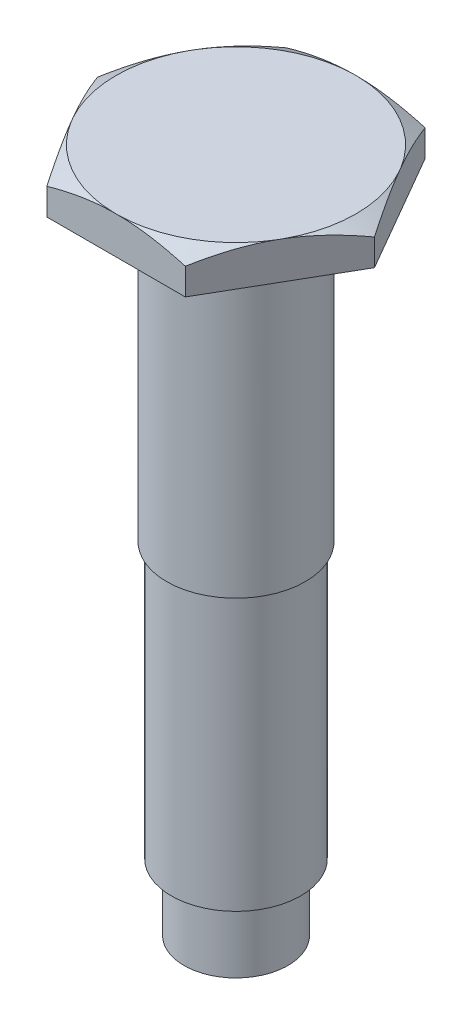
from build123d import *

# Parameters (mm, degrees)
BOSS_EXTRUDE1_DEPTH = 1.4
SKETCH2_OUTSIDE_W   = 18.618
SKETCH2_OUTSIDE_H   = 17.226
SKETCH2_OUTSIDE_R   = 4.5
CUT_EXTRUDE1_DEPTH  = 1
CUT_EXTRUDE1_TAPER  = 60
SKETCH3_R           = 2.425
BOSS_EXTRUDE2_DEPTH = 24.3
SKETCH4_OUTSIDE_W   = 18.218
SKETCH4_OUTSIDE_H   = 16.826
SKETCH4_OUTSIDE_R   = 1.95
CUT_EXTRUDE2_DEPTH  = 2.5
SKETCH5_R           = 2.6
BOSS_EXTRUDE3_DEPTH = 11.5


with BuildPart() as part:
    # Sketch1 → Boss-Extrude1 (new body)
    with BuildSketch(Plane(origin=(0, 0, 0), x_dir=(1, 0, 0), z_dir=(0, 1, 0))):
        Polygon((5.195, 0), (2.5975, 4.499001973), (-2.5975, 4.499001973), (-5.195, 0), (-2.5975, -4.499001973), (2.5975, -4.499001973), align=None)
    extrude(amount=BOSS_EXTRUDE1_DEPTH)

    # Sketch2 outside → Cut-Extrude1 (cut)
    with BuildSketch(Plane(origin=(0, 1.4, 0), x_dir=(1, 0, 0), z_dir=(0, 1, 0))):
        Rectangle(SKETCH2_OUTSIDE_W, SKETCH2_OUTSIDE_H)
        Circle(SKETCH2_OUTSIDE_R, mode=Mode.SUBTRACT)
    extrude(amount=-CUT_EXTRUDE1_DEPTH, taper=CUT_EXTRUDE1_TAPER, mode=Mode.SUBTRACT)

    # Sketch3 → Boss-Extrude2 (add)
    with BuildSketch(Plane.XZ):
        Circle(SKETCH3_R)
    extrude(amount=BOSS_EXTRUDE2_DEPTH)

    # Sketch4 outside → Cut-Extrude2 (cut)
    with BuildSketch(Plane.XZ.offset(24.3)):
        Rectangle(SKETCH4_OUTSIDE_W, SKETCH4_OUTSIDE_H)
        Circle(SKETCH4_OUTSIDE_R, mode=Mode.SUBTRACT)
    extrude(amount=-CUT_EXTRUDE2_DEPTH, mode=Mode.SUBTRACT)

    # Sketch5 → Boss-Extrude3 (add)
    with BuildSketch(Plane.XZ):
        Circle(SKETCH5_R)
    extrude(amount=BOSS_EXTRUDE3_DEPTH)


solid = part.part
